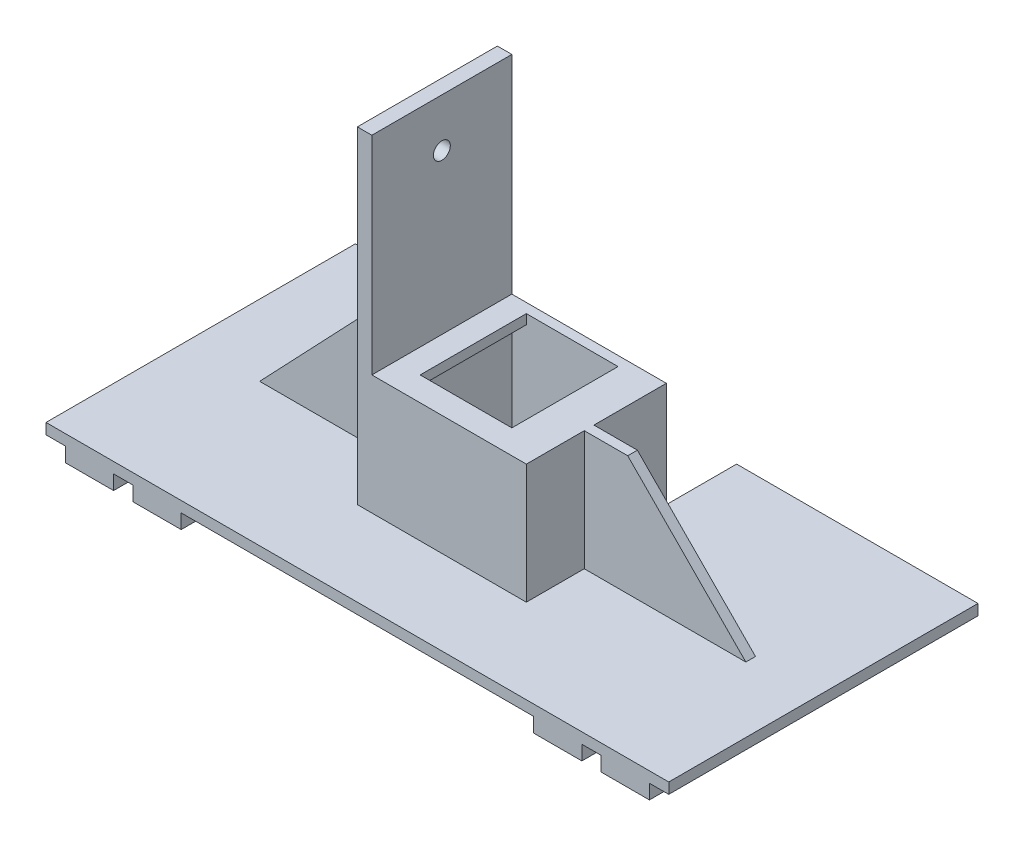
from build123d import *

# Parameters (mm, degrees)
SKETCH1_W                 = 29
SKETCH1_H                 = 27
BOSS_EXTRUDE2_DEPTH       = 2
SKETCH2_W                 = 2
SKETCH2_H                 = 27
BOSS_EXTRUDE3_DEPTH       = 27
SKETCH3_W                 = 2
SKETCH3_H                 = 27
BOSS_EXTRUDE4_DEPTH       = 27
SKETCH4_W                 = 2
SKETCH4_H                 = 27
BOSS_EXTRUDE5_DEPTH       = 29
SKETCH5_W                 = 29
SKETCH5_H                 = 2
BOSS_EXTRUDE6_DEPTH       = 5
SKETCH6_W                 = 29
SKETCH6_H                 = 2
BOSS_EXTRUDE7_DEPTH       = 5
SKETCH7_W                 = 29
SKETCH7_H                 = 2
BOSS_EXTRUDE9_DEPTH       = 3
SKETCH8_W                 = 29
SKETCH8_H                 = 70
BOSS_EXTRUDE10_DEPTH      = 3
SKETCH9_W                 = 29
SKETCH9_H                 = 70
BOSS_EXTRUDE11_DEPTH      = 3
SKETCH10_R                = 1.75
CUT_EXTRUDE1_DEPTH        = 40
CUT_EXTRUDE1_DEPTH_BACK   = 4
SKETCH14_W                = 64.059186105
SKETCH14_H                = 2.228166541
BOSS_EXTRUDE15_DEPTH      = 50
SKETCH15_W                = 64.059186105
SKETCH15_H                = 2.228166541
BOSS_EXTRUDE16_DEPTH      = 50
SKETCH16_W                = 17.5
SKETCH16_H                = 2.228166541
BOSS_EXTRUDE17_DEPTH      = 29
BOSS_EXTRUDE18_DEPTH      = 1
BOSS_EXTRUDE18_DEPTH_BACK = 1
SKETCH19_W                = 29
SKETCH19_H                = 43
CUT_EXTRUDE2_DEPTH        = 15
SKETCH20_W                = 10
SKETCH20_H                = 64.059186105
BOSS_EXTRUDE19_DEPTH      = 3
SKETCH21_R                = 1.75
BOSS_EXTRUDE20_DEPTH      = 4


with BuildPart() as part:
    # Sketch1 → Boss-Extrude2 (new body)
    with BuildSketch(Plane.XY):
        with Locations((14.5, 13.5)):
            Rectangle(SKETCH1_W, SKETCH1_H)
    extrude(amount=BOSS_EXTRUDE2_DEPTH)

    # Sketch2 → Boss-Extrude3 (add)
    with BuildSketch(Plane.XY):
        with Locations((1, 13.5)):
            Rectangle(SKETCH2_W, SKETCH2_H)
    extrude(amount=-BOSS_EXTRUDE3_DEPTH)

    # Sketch3 → Boss-Extrude4 (add)
    with BuildSketch(Plane.XY):
        with Locations((28, 13.5)):
            Rectangle(SKETCH3_W, SKETCH3_H)
    extrude(amount=-BOSS_EXTRUDE4_DEPTH)

    # Sketch4 → Boss-Extrude5 (add)
    with BuildSketch(Plane(origin=(0, 0, 0), x_dir=(0, 0, -1), z_dir=(1, 0, 0))):
        with Locations((26, 13.5)):
            Rectangle(SKETCH4_W, SKETCH4_H)
    extrude(amount=BOSS_EXTRUDE5_DEPTH)

    # Sketch5 → Boss-Extrude6 (add)
    with BuildSketch(Plane(origin=(0, 0, 0), x_dir=(0, 0, -1), z_dir=(1, 0, 0))):
        with Locations((12.5, 26)):
            Rectangle(SKETCH5_W, SKETCH5_H)
    extrude(amount=BOSS_EXTRUDE6_DEPTH)

    # Sketch6 → Boss-Extrude7 (add)
    with BuildSketch(Plane(origin=(29, 0, 0), x_dir=(0, 0, -1), z_dir=(1, 0, 0))):
        with Locations((12.5, 26)):
            Rectangle(SKETCH6_W, SKETCH6_H)
    extrude(amount=-BOSS_EXTRUDE7_DEPTH)

    # Sketch7 → Boss-Extrude9 (add)
    with BuildSketch(Plane.XY):
        with Locations((14.5, 26)):
            Rectangle(SKETCH7_W, SKETCH7_H)
    extrude(amount=-BOSS_EXTRUDE9_DEPTH)

    # Sketch8 → Boss-Extrude10 (add)
    with BuildSketch(Plane(origin=(0, 0, 0), x_dir=(0, 0, -1), z_dir=(1, 0, 0))):
        with Locations((12.5, 35)):
            Rectangle(SKETCH8_W, SKETCH8_H)
    extrude(amount=-BOSS_EXTRUDE10_DEPTH)

    # Sketch9 → Boss-Extrude11 (add)
    with BuildSketch(Plane(origin=(29, 0, 0), x_dir=(0, 0, -1), z_dir=(1, 0, 0))):
        with Locations((12.5, 35)):
            Rectangle(SKETCH9_W, SKETCH9_H)
    extrude(amount=BOSS_EXTRUDE11_DEPTH)

    # Sketch10 → Cut-Extrude1 (cut, two sides)
    with BuildSketch(Plane(origin=(0, 0, 0), x_dir=(0, 0, -1), z_dir=(1, 0, 0))) as cut_extrude1_sk:
        with Locations((12.5, 60)):
            Circle(SKETCH10_R)
    extrude(amount=CUT_EXTRUDE1_DEPTH, mode=Mode.SUBTRACT)
    extrude(cut_extrude1_sk.sketch, amount=-CUT_EXTRUDE1_DEPTH_BACK, mode=Mode.SUBTRACT)

    # Sketch14 → Boss-Extrude15 (add)
    with BuildSketch(Plane(origin=(29, 0, 0), x_dir=(0, 0, -1), z_dir=(1, 0, 0))):
        with Locations((12.529593053, 1.114083271)):
            Rectangle(SKETCH14_W, SKETCH14_H)
    extrude(amount=BOSS_EXTRUDE15_DEPTH)

    # Sketch15 → Boss-Extrude16 (add)
    with BuildSketch(Plane(origin=(0, 0, 0), x_dir=(0, 0, -1), z_dir=(1, 0, 0))):
        with Locations((12.529593053, 1.114083271)):
            Rectangle(SKETCH15_W, SKETCH15_H)
    extrude(amount=-BOSS_EXTRUDE16_DEPTH)

    # Sketch16 → Boss-Extrude17 (add)
    with BuildSketch(Plane(origin=(0, 0, 0), x_dir=(0, 0, -1), z_dir=(1, 0, 0))):
        with Locations((-10.75, 1.114083271)):
            Rectangle(SKETCH16_W, SKETCH16_H)
    extrude(amount=BOSS_EXTRUDE17_DEPTH)

    # Sketch18 → Boss-Extrude18 (add, two sides)
    with BuildSketch(Plane.XY.offset(-11)) as boss_extrude18_sk:
        Polygon((-35.241827575, 2.228166541), (-3, 2.228166541), (-3, 36.114083271), align=None)
        Polygon((32, 2.228166541), (65.471342827, 2.228166541), (32, 36.114083271), align=None)
    extrude(amount=BOSS_EXTRUDE18_DEPTH)
    extrude(boss_extrude18_sk.sketch, amount=-BOSS_EXTRUDE18_DEPTH_BACK)

    # Sketch19 → Cut-Extrude2 (cut)
    with BuildSketch(Plane(origin=(29, 0, 0), x_dir=(0, 0, -1), z_dir=(1, 0, 0))):
        with Locations((12.5, 48.5)):
            Rectangle(SKETCH19_W, SKETCH19_H)
    extrude(amount=CUT_EXTRUDE2_DEPTH, mode=Mode.SUBTRACT)

    # Sketch20 → Boss-Extrude19 (add)
    with BuildSketch(Plane(origin=(0, 0, 0), x_dir=(1, 0, 0), z_dir=(0, 1, 0))):
        with Locations((-41, 12.529593053)):
            Rectangle(SKETCH20_W, SKETCH20_H)
        with Locations((-27, 12.529593053)):
            Rectangle(SKETCH20_W, SKETCH20_H)
        with Locations((70, 12.529593053)):
            Rectangle(SKETCH20_W, SKETCH20_H)
        with Locations((56, 12.529593053)):
            Rectangle(SKETCH20_W, SKETCH20_H)
    extrude(amount=-BOSS_EXTRUDE19_DEPTH)

    # Sketch21 → Boss-Extrude20 (add)
    with BuildSketch(Plane(origin=(0, 0, 0), x_dir=(1, 0, 0), z_dir=(0, 1, 0))):
        with Locations((-41, 29.559186105)):
            Circle(SKETCH21_R)
        with Locations((-41, 12.559186105)):
            Circle(SKETCH21_R)
        with Locations((-41, -4.5)):
            Circle(SKETCH21_R)
        with Locations((-27, 29.559186105)):
            Circle(SKETCH21_R)
        with Locations((-27, 12.559186105)):
            Circle(SKETCH21_R)
        with Locations((-27, -4.5)):
            Circle(SKETCH21_R)
        with Locations((56, 29.559186105)):
            Circle(SKETCH21_R)
        with Locations((56, 12.559186105)):
            Circle(SKETCH21_R)
        with Locations((56, -4.5)):
            Circle(SKETCH21_R)
        with Locations((70, 29.559186105)):
            Circle(SKETCH21_R)
        with Locations((70, 12.559186105)):
            Circle(SKETCH21_R)
        with Locations((70, -4.5)):
            Circle(SKETCH21_R)
    extrude(amount=-BOSS_EXTRUDE20_DEPTH)


solid = part.part
